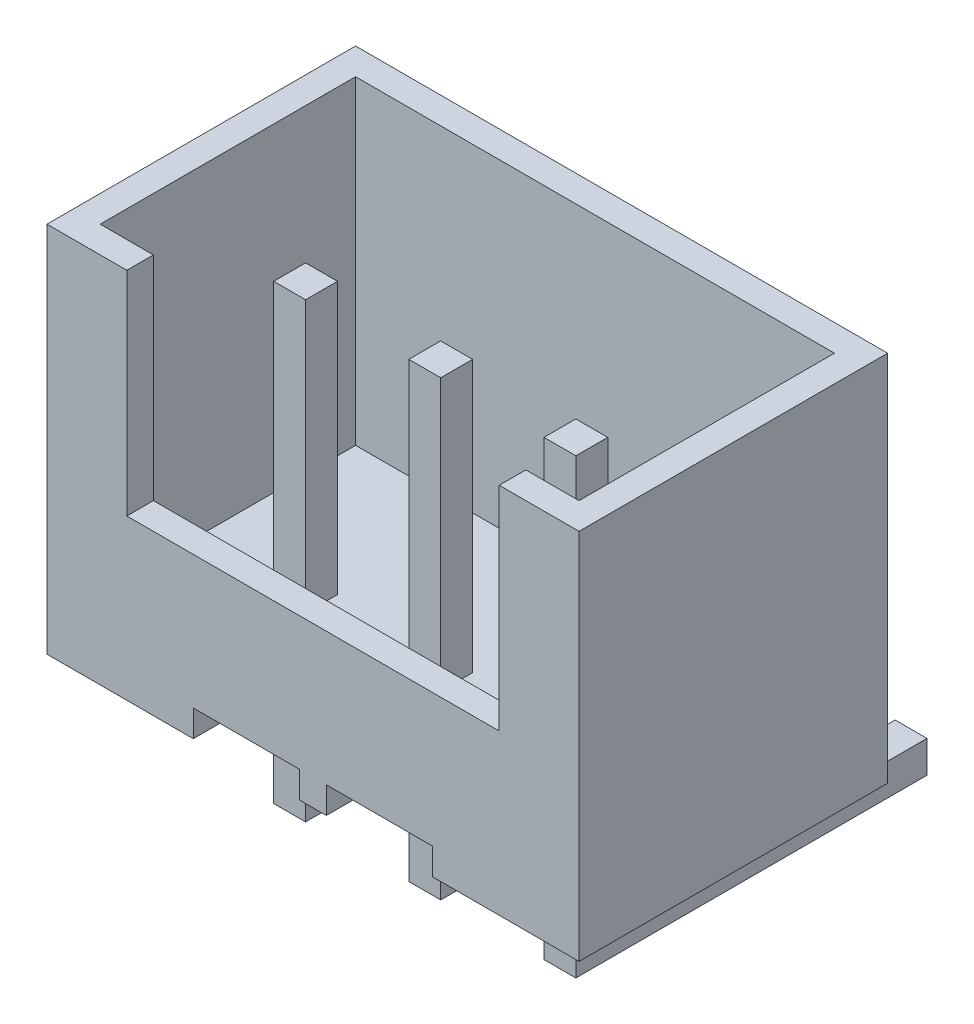
from build123d import *

# Parameters (mm, degrees)
EXTRUDE_1_DEPTH      = 5.8
SKETCH_2_W           = 9
SKETCH_2_H           = 4.8
CUT_EXTRUDE_1_DEPTH  = 6
SKETCH_3_W           = 0.6
SKETCH_3_H           = 0.6
EXTRUDE_2_DEPTH      = 2.4
EXTRUDE_2_DEPTH_BACK = 6.1
SKETCH_5_W           = 7
SKETCH_5_H           = 4
CUT_EXTRUDE_2_DEPTH  = 1
SKETCH_6_W           = 0.6
SKETCH_6_H           = 0.6
EXTRUDE_3_DEPTH      = 6


with BuildPart() as part:
    # 草图1 → 凸台-拉伸1 (new body)
    with BuildSketch(Plane.XY):
        Polygon((2.75, 0), (2.75, 0.5), (4.75, 0.5), (4.75, 0), (5.25, 0), (5.25, 0.5), (7.25, 0.5), (7.25, 0), (10, 0), (10, 7), (0, 7), (0, 0), align=None)
    extrude(amount=EXTRUDE_1_DEPTH)

    # 草图2 → 切除-拉伸1 (cut)
    with BuildSketch(Plane(origin=(0, 7, 0), x_dir=(1, 0, 0), z_dir=(0, 1, 0))):
        with Locations((5, -2.9)):
            Rectangle(SKETCH_2_W, SKETCH_2_H)
    extrude(amount=-CUT_EXTRUDE_1_DEPTH, mode=Mode.SUBTRACT)

    # 草图3 → 凸台-拉伸2 (add, two sides)
    with BuildSketch(Plane.XZ) as extrude_2_sk:
        with Locations((2.46, 3.4)):
            Rectangle(SKETCH_3_W, SKETCH_3_H)
        with Locations((5, 3.4)):
            Rectangle(SKETCH_3_W, SKETCH_3_H)
        with Locations((7.54, 3.4)):
            Rectangle(SKETCH_3_W, SKETCH_3_H)
    extrude(amount=EXTRUDE_2_DEPTH)
    extrude(extrude_2_sk.sketch, amount=-EXTRUDE_2_DEPTH_BACK)

    # 草图5 → 切除-拉伸2 (cut)
    with BuildSketch(Plane.XY.offset(5.8)):
        with Locations((5, 5)):
            Rectangle(SKETCH_5_W, SKETCH_5_H)
    extrude(amount=-CUT_EXTRUDE_2_DEPTH, mode=Mode.SUBTRACT)

    # 草图6 → 凸台-拉伸3 (add)
    with BuildSketch(Plane(origin=(0, 0, 3.1), x_dir=(-1, 0, 0), z_dir=(0, 0, -1))):
        with Locations((-2.46, -2.1)):
            Rectangle(SKETCH_6_W, SKETCH_6_H)
        with Locations((-5, -2.1)):
            Rectangle(SKETCH_6_W, SKETCH_6_H)
        with Locations((-7.54, -2.1)):
            Rectangle(SKETCH_6_W, SKETCH_6_H)
    extrude(amount=EXTRUDE_3_DEPTH)


solid = part.part
